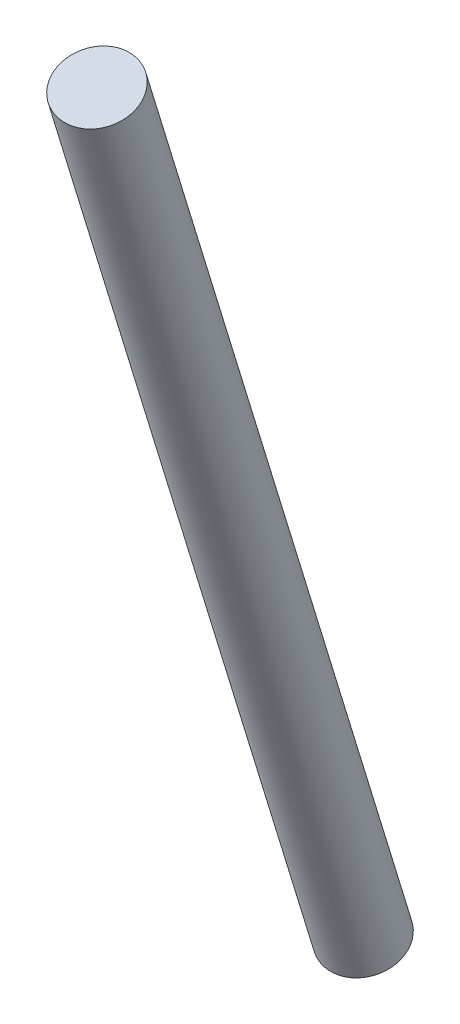
from build123d import *

# Parameters (mm, degrees)
SWEEP1_PROFILE_R = 17.145


with BuildPart() as part:
    # Sweep1: sweep along a curve in space
    with BuildLine() as sweep1_path:
        Line((164.278526781, 112.063669757, 175.582551715), (208.728526781, 568.237895888, 346.22225237))
    # Sweep1 profile (on start of the path) → Sweep1 (sweep)
    with BuildSketch(Plane(origin=(164.278526781, 112.063669757, 175.582551715), x_dir=(0, -0.350357155, 0.936616177), z_dir=(0.090886943, 0.932739726, 0.348907103))):
        Circle(SWEEP1_PROFILE_R)
    sweep(path=sweep1_path.line)


solid = part.part
